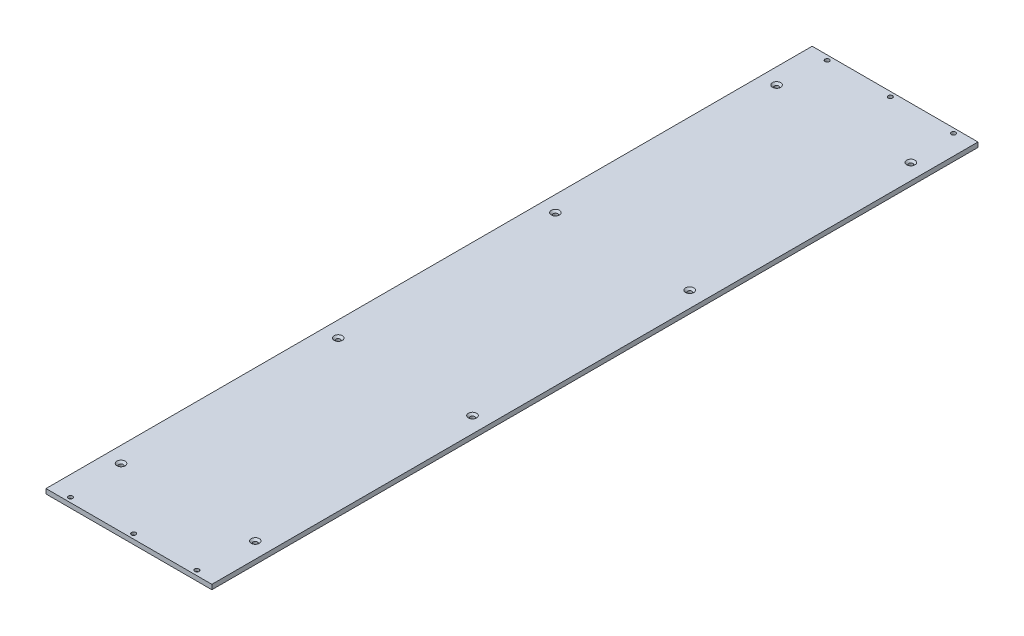
from build123d import *

# Parameters (mm, degrees)
SKETCH1_W                                       = 210
SKETCH1_H                                       = 970
BOSS_EXTRUDE1_DEPTH                             = 6
CSK_FOR_M5_FLAT_HEAD_MACHINE_SCREW1_D           = 5.5
CSK_FOR_M5_FLAT_HEAD_MACHINE_SCREW1_CSINK_D     = 10.4
CSK_FOR_M5_FLAT_HEAD_MACHINE_SCREW1_CSINK_ANGLE = 90
LPATTERN1_COUNT                                 = 3
LPATTERN1_PITCH                                 = 275
LPATTERN2_COUNT                                 = 2
LPATTERN2_PITCH                                 = 830
MIRROR1_COPY_1_D                                = 5.5
MIRROR1_COPY_1_CSINK_D                          = 10.4
MIRROR1_COPY_1_CSINK_ANGLE                      = 90
MIRROR1_COPY_2_D                                = 5.5
MIRROR1_COPY_2_CSINK_D                          = 10.4
MIRROR1_COPY_2_CSINK_ANGLE                      = 90
MIRROR1_COPY_3_D                                = 5.5
MIRROR1_COPY_3_CSINK_D                          = 10.4
MIRROR1_COPY_3_CSINK_ANGLE                      = 90
CSK_FOR_M5_FLAT_HEAD_MACHINE_SCREW2_D           = 5.5
CSK_FOR_M5_FLAT_HEAD_MACHINE_SCREW2_CSINK_D     = 10.4
CSK_FOR_M5_FLAT_HEAD_MACHINE_SCREW2_CSINK_ANGLE = 90


with BuildPart() as part:
    # Sketch1 → Boss-Extrude1 (new body)
    with BuildSketch(Plane(origin=(0, 0, 0), x_dir=(1, 0, 0), z_dir=(0, 1, 0))):
        with Locations((105, 485)):
            Rectangle(SKETCH1_W, SKETCH1_H)
    extrude(amount=BOSS_EXTRUDE1_DEPTH)

    # CSK for M5 Flat Head Machine Screw1 (through all)
    with Locations(Plane(origin=(0, 6, 0), x_dir=(1, 0, 0), z_dir=(0, 1, 0))):
        with Locations((20, 75)):
            csk_for_m5_flat_head_machine_screw1 = CounterSinkHole(CSK_FOR_M5_FLAT_HEAD_MACHINE_SCREW1_D / 2, CSK_FOR_M5_FLAT_HEAD_MACHINE_SCREW1_CSINK_D / 2, counter_sink_angle=CSK_FOR_M5_FLAT_HEAD_MACHINE_SCREW1_CSINK_ANGLE)

    # LPattern1: CSK for M5 Flat Head Machine Screw1 ×3
    with Locations(*[(0, 0, -i * LPATTERN1_PITCH) for i in range(1, LPATTERN1_COUNT)]):
        add(csk_for_m5_flat_head_machine_screw1, mode=Mode.SUBTRACT)

    # LPattern2: CSK for M5 Flat Head Machine Screw1 ×2
    with Locations(*[(0, 0, -i * LPATTERN2_PITCH) for i in range(1, LPATTERN2_COUNT)]):
        add(csk_for_m5_flat_head_machine_screw1, mode=Mode.SUBTRACT)

    # Mirror1: CSK for M5 Flat Head Machine Screw1 across plane
    add(csk_for_m5_flat_head_machine_screw1.mirror(Plane(origin=(105, 0, 0), x_dir=(0, 0, 1), z_dir=(1, 0, 0))), mode=Mode.SUBTRACT)

    # Mirror1 copy 1 (through all)
    with Locations(Plane(origin=(210, 6, -830), x_dir=(-1, 0, 0), z_dir=(0, 1, 0))):
        with Locations((20, -75)):
            CounterSinkHole(MIRROR1_COPY_1_D / 2, MIRROR1_COPY_1_CSINK_D / 2, counter_sink_angle=MIRROR1_COPY_1_CSINK_ANGLE)

    # Mirror1 copy 2 (through all)
    with Locations(Plane(origin=(210, 6, -275), x_dir=(-1, 0, 0), z_dir=(0, 1, 0))):
        with Locations((20, -75)):
            CounterSinkHole(MIRROR1_COPY_2_D / 2, MIRROR1_COPY_2_CSINK_D / 2, counter_sink_angle=MIRROR1_COPY_2_CSINK_ANGLE)

    # Mirror1 copy 3 (through all)
    with Locations(Plane(origin=(210, 6, -550), x_dir=(-1, 0, 0), z_dir=(0, 1, 0))):
        with Locations((20, -75)):
            CounterSinkHole(MIRROR1_COPY_3_D / 2, MIRROR1_COPY_3_CSINK_D / 2, counter_sink_angle=MIRROR1_COPY_3_CSINK_ANGLE)

    # CSK for M5 Flat Head Machine Screw2 (through all)
    with Locations(Plane(origin=(0, 0, 0), x_dir=(-1, 0, 0), z_dir=(0, -1, 0))):
        with Locations((-25, 6), (-185, 6), (-105, 6)):
            csk_for_m5_flat_head_machine_screw2 = CounterSinkHole(CSK_FOR_M5_FLAT_HEAD_MACHINE_SCREW2_D / 2, CSK_FOR_M5_FLAT_HEAD_MACHINE_SCREW2_CSINK_D / 2, counter_sink_angle=CSK_FOR_M5_FLAT_HEAD_MACHINE_SCREW2_CSINK_ANGLE)

    # Mirror2: CSK for M5 Flat Head Machine Screw2 across plane
    add(csk_for_m5_flat_head_machine_screw2.mirror(Plane(origin=(0, 0, -485), x_dir=(1, 0, 0), z_dir=(0, 0, -1))), mode=Mode.SUBTRACT)


solid = part.part
